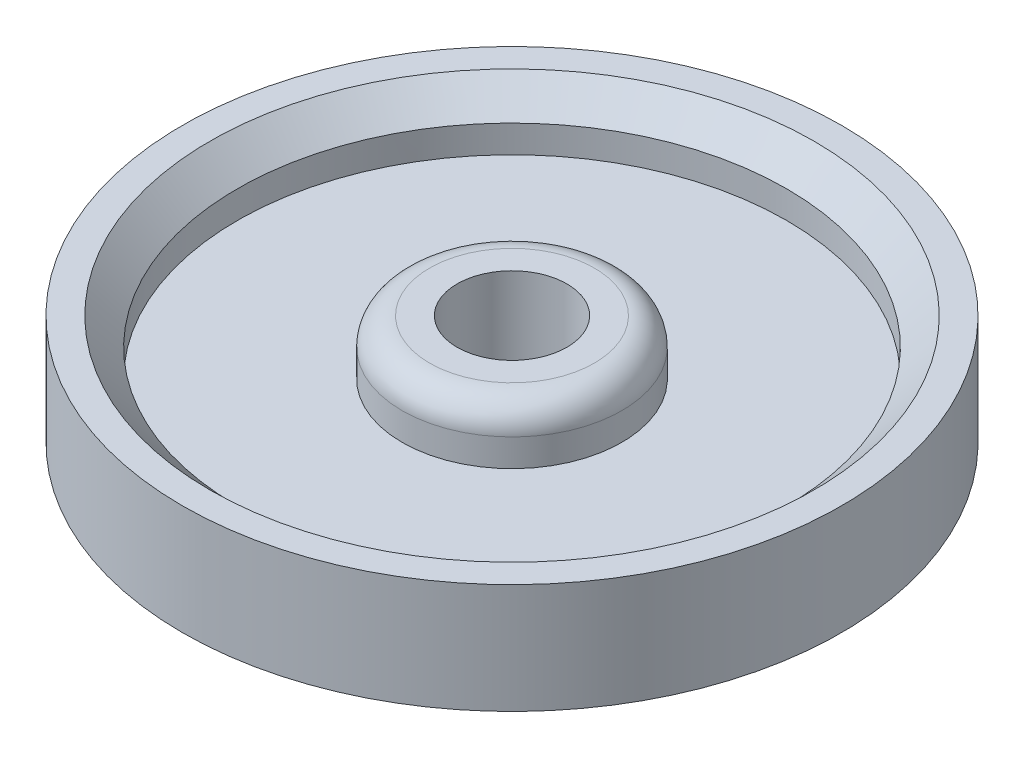
from build123d import *

# Parameters (mm, degrees)
ESQUISSE1_R             = 20
BOSS_EXTRU_1_DEPTH      = 20
ESQUISSE1_R_2           = 60
ESQUISSE1_R_3           = 50
BOSS_EXTRU_1_2_DEPTH    = 20
ESQUISSE2_R             = 50
ESQUISSE2_R_2           = 20
BOSS_EXTRU_2_DEPTH      = 10
CHANFREIN1_SIZE         = 5
CONG_1_R                = 5
ESQUISSE3_R             = 10
ENL_V_MAT_EXTRU_1_DEPTH = 82


with BuildPart() as part:
    # Esquisse1 → Boss.-Extru.1 (new body)
    with BuildSketch(Plane(origin=(0, 0, 0), x_dir=(1, 0, 0), z_dir=(0, 1, 0))):
        with Locations((24.301532902, 9.851972798)):
            Circle(ESQUISSE1_R)
    extrude(amount=BOSS_EXTRU_1_DEPTH)



with BuildPart() as body_2:
    # Esquisse1 → Boss.-Extru.1 2 (new body)
    with BuildSketch(Plane(origin=(0, 0, 0), x_dir=(1, 0, 0), z_dir=(0, 1, 0))):
        with Locations((24.301532902, 9.851972798)):
            Circle(ESQUISSE1_R_2)
        with Locations((24.301532902, 9.851972798)):
            Circle(ESQUISSE1_R_3, mode=Mode.SUBTRACT)
    extrude(amount=BOSS_EXTRU_1_2_DEPTH)


with BuildPart() as part_1:
    add(part.part)

    add(body_2.part)  # Boss.-Extru.2 merges body 2
    # Esquisse2 → Boss.-Extru.2 (add)
    with BuildSketch(Plane.XZ):
        with Locations((24.301532902, -9.851972798)):
            Circle(ESQUISSE2_R)
        with Locations((24.301532902, -9.851972798)):
            Circle(ESQUISSE2_R_2, mode=Mode.SUBTRACT)
    extrude(amount=-BOSS_EXTRU_2_DEPTH)

    # Chanfrein1
    chanfrein1_edges = [part_1.edges().sort_by_distance(p)[0] for p in [
        (-25.698467098, 20, -9.851972798),
    ]]
    chamfer(chanfrein1_edges, length=CHANFREIN1_SIZE)

    # Congé1
    cong_1_edges = [part_1.edges().sort_by_distance(p)[0] for p in [
        (4.301532902, 20, -9.851972798),
    ]]
    fillet(cong_1_edges, radius=CONG_1_R)

    # Esquisse3 → Enlèv. mat.-Extru.1 (cut)
    with BuildSketch(Plane(origin=(0, 20, 0), x_dir=(1, 0, 0), z_dir=(0, 1, 0))):
        with Locations((24.301532902, 9.851972798)):
            Circle(ESQUISSE3_R)
    extrude(amount=-ENL_V_MAT_EXTRU_1_DEPTH, mode=Mode.SUBTRACT)


solid = part_1.part
